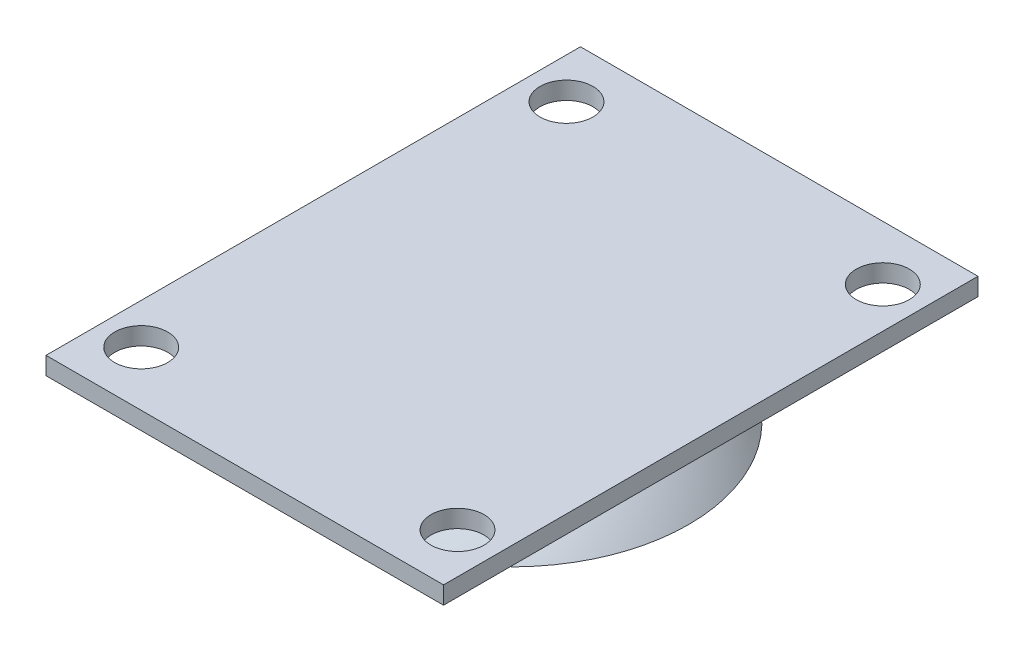
from build123d import *

# Parameters (mm, degrees)
SKETCH1_W           = 45
SKETCH1_H           = 60.5
SKETCH1_R           = 3
BOSS_EXTRUDE1_DEPTH = 2


with BuildPart() as part:
    # Sketch1 → Boss-Extrude1 (new body)
    with BuildSketch(Plane(origin=(0, 0, 0), x_dir=(1, 0, 0), z_dir=(0, 1, 0))):
        Rectangle(SKETCH1_W, SKETCH1_H)
        with Locations((17.904367565, 24.071427504)):
            Circle(SKETCH1_R, mode=Mode.SUBTRACT)
        with Locations((-17.904367565, 24.071427504)):
            Circle(SKETCH1_R, mode=Mode.SUBTRACT)
        with Locations((17.904367565, -24.071427504)):
            Circle(SKETCH1_R, mode=Mode.SUBTRACT)
        with Locations((-17.904367565, -24.071427504)):
            Circle(SKETCH1_R, mode=Mode.SUBTRACT)
    extrude(amount=BOSS_EXTRUDE1_DEPTH)


with BuildPart() as body_2:
    # Sketch2 → Revolve1 (revolve)
    with BuildSketch(Plane.XY):
        with BuildLine():
            Line((0, -2.019980921), (1.99930643, -2.072647775))
            add(Edge.make_bspline(
                [(1.99930643, -2.072647775), (2.666007666, -2.117291662), (4.014019168, -2.251616435), (6.549499982, -2.683388344), (9.525407915, -3.533799384), (12.765394617, -5.035648817), (14.749449818, -6.380365871), (15.679001727, -7.124399167)],
                knots=[0.08723148, 0.08723148, 0.08723148, 0.08723148, 0.177417467, 0.267603454, 0.447975427, 0.628347401, 0.808719374, 0.808719374, 0.808719374, 0.808719374], degree=3))
            Line((15.679001727, -7.124399167), (17.160402388, -8.468070288))
            Line((17.160402388, -8.468070288), (20, -8.468070288))
            add(Edge.make_bspline(
                [(0, 0), (12.43840622, -0.079628335), (20, -8.468070288)],
                knots=[0, 0, 0, 1, 1, 1], degree=2))
            Line((0, 0), (0, -2.019980921))
        make_face()
    revolve(axis=Axis((0, 10.005953766, 0), (0, -1, 0)))


solid = Compound([part.part, body_2.part])
